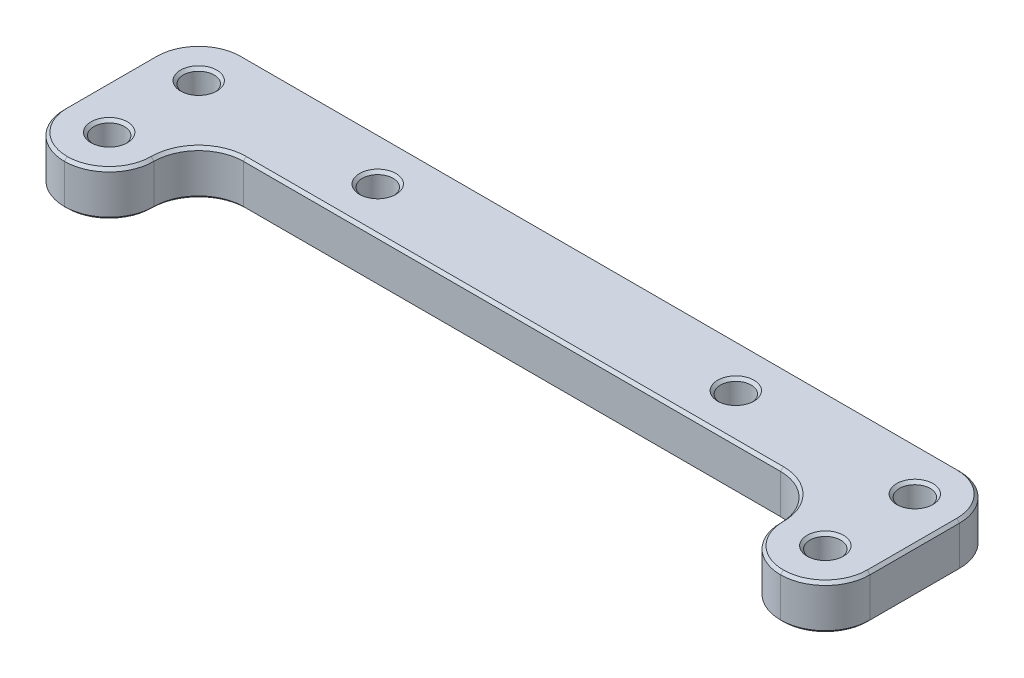
from build123d import *

# Parameters (mm, degrees)
SKETCH1_R           = 2.1828125
BOSS_EXTRUDE1_DEPTH = 6.35
CHAMFER1_SIZE       = 0.396875


with BuildPart() as part:
    # Sketch1 → Boss-Extrude1 (new body)
    with BuildSketch(Plane(origin=(0, 0, 0), x_dir=(1, 0, 0), z_dir=(0, 1, 0))):
        with BuildLine():
            Line((-101.600254, 6.35), (0.000254, 6.35))
            ThreePointArc((0.000254, 6.35), (4.490202455, 4.490202455), (6.35, 0.000254))
            Line((6.35, 0.000254), (6.35, -12.700254))
            ThreePointArc((6.35, -12.700254), (4.490202455, -17.190202455), (0.000254, -19.05))
            ThreePointArc((0.000254, -19.05), (-4.490202455, -17.190202455), (-6.35, -12.700254))
            ThreePointArc((-6.35, -12.700254), (-8.209797545, -8.209797545), (-12.699746, -6.35))
            Line((-12.699746, -6.35), (-88.900254, -6.35))
            ThreePointArc((-88.900254, -6.35), (-93.390202455, -8.209797545), (-95.25, -12.699746))
            ThreePointArc((-95.25, -12.699746), (-97.109797545, -17.190202455), (-101.599746, -19.05))
            ThreePointArc((-101.599746, -19.05), (-106.090202455, -17.190202455), (-107.95, -12.700254))
            Line((-107.95, -12.700254), (-107.95, 0.000254))
            ThreePointArc((-107.95, 0.000254), (-106.090202455, 4.490202455), (-101.600254, 6.35))
        make_face()
        Circle(SKETCH1_R, mode=Mode.SUBTRACT)
        with Locations((-25.4, 0)):
            Circle(SKETCH1_R, mode=Mode.SUBTRACT)
        with Locations((-76.2, 0)):
            Circle(SKETCH1_R, mode=Mode.SUBTRACT)
        with Locations((-101.6, 0)):
            Circle(SKETCH1_R, mode=Mode.SUBTRACT)
        with Locations((-101.6, -12.7)):
            Circle(SKETCH1_R, mode=Mode.SUBTRACT)
        with Locations((0, -12.7)):
            Circle(SKETCH1_R, mode=Mode.SUBTRACT)
    extrude(amount=BOSS_EXTRUDE1_DEPTH)

    # Chamfer1
    chamfer1_edges = [part.edges().sort_by_distance(p)[0] for p in [
        (-4.490022844, 6.35, 17.19038206),
        (-50.8, 0, 6.35),
        (-93.390202455, 0, 8.209797545),
        (-97.10961794, 0, 17.190022844),
        (-4.490022844, 6.35, 17.19038206),
        (-97.10961794, 0, 17.190022844),
        (-106.090022844, 0, 17.19038206),
        (-106.090022844, 0, 17.19038206),
        (-107.95, 0, 6.35),
        (-106.090202455, 0, -4.490202455),
        (-50.8, 0, -6.35),
        (4.490202455, 0, -4.490202455),
        (6.35, 0, 6.35),
        (4.490202455, 0, 17.190202455),
        (-4.490022844, 0, 17.19038206),
        (4.490202455, 6.35, 17.190202455),
        (-4.490022844, 0, 17.19038206),
        (-8.20961794, 0, 8.209977156),
        (-8.20961794, 0, 8.209977156),
        (6.35, 6.35, 6.35),
        (4.490202455, 6.35, -4.490202455),
        (-50.8, 6.35, -6.35),
        (-106.090202455, 6.35, -4.490202455),
        (-2.1828125, 0, 0),
        (-2.1828125, 6.35, 0),
        (-107.95, 6.35, 6.35),
        (-27.5828125, 0, 0),
        (-27.5828125, 6.35, 0),
        (-106.090022844, 6.35, 17.19038206),
        (-78.3828125, 0, 0),
        (-78.3828125, 6.35, 0),
        (-106.090022844, 6.35, 17.19038206),
        (-8.20961794, 6.35, 8.209977156),
        (-103.7828125, 0, 0),
        (-103.7828125, 6.35, 0),
        (-97.10961794, 6.35, 17.190022844),
        (-103.7828125, 0, 12.7),
        (-103.7828125, 6.35, 12.7),
        (-97.10961794, 6.35, 17.190022844),
        (-2.1828125, 0, 12.7),
        (-2.1828125, 6.35, 12.7),
        (-93.390202455, 6.35, 8.209797545),
        (-50.8, 6.35, 6.35),
        (-8.20961794, 6.35, 8.209977156),
    ]]
    chamfer(chamfer1_edges, length=CHAMFER1_SIZE)


solid = part.part
